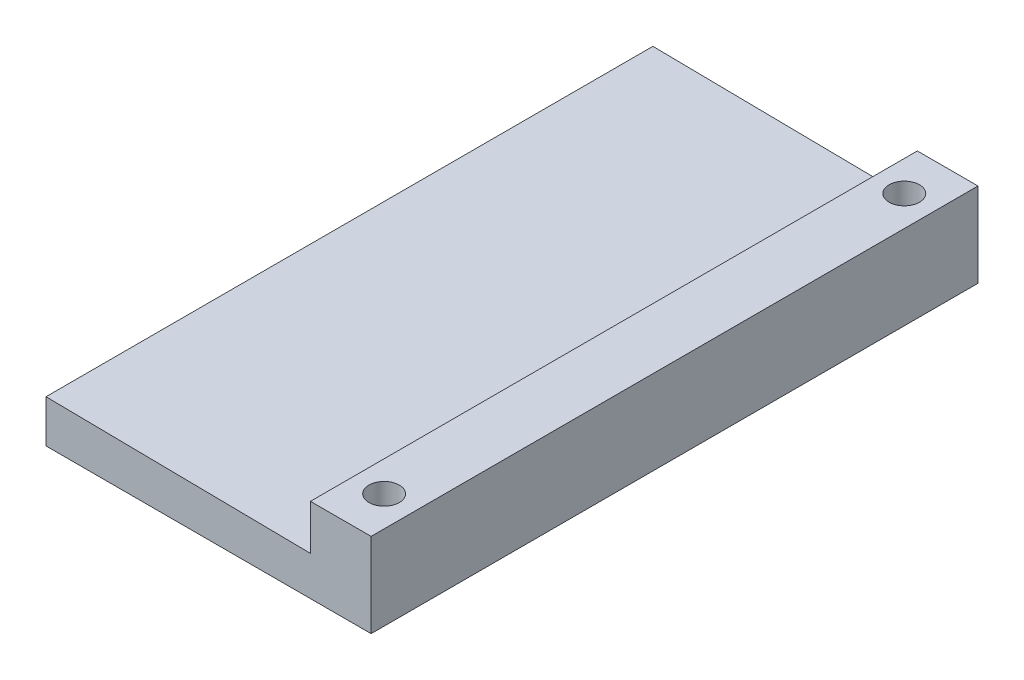
from build123d import *

# Parameters (mm, degrees)
SKETCH1_W               = 41.275
SKETCH1_H               = 88.9
BOSS_EXTRUDE1_DEPTH     = 5.9944
SKETCH1_5_W             = 8.89
SKETCH1_5_H             = 88.9
BOSS_EXTRUDE2_DEPTH     = 12.3444
SKETCH3_R               = 2.2225
CUT_EXTRUDE1_DEPTH      = 1
CUT_EXTRUDE1_DEPTH_BACK = 13.3444
SKETCH4_R               = 3.683
CUT_EXTRUDE2_DEPTH      = 4.064
SKETCH5_W               = 2.54
SKETCH5_H               = 88.9
CUT_EXTRUDE3_DEPTH      = 7.35
CUT_EXTRUDE3_DEPTH_BACK = 6.9944
BOSS_EXTRUDE3_DEPTH     = 88.9
CUT_EXTRUDE4_DEPTH      = 88.9


with BuildPart() as part:
    # Sketch1 → Boss-Extrude1 (new body)
    with BuildSketch(Plane(origin=(0, 0, 0), x_dir=(1, 0, 0), z_dir=(0, 1, 0))):
        with Locations((20.6375, 44.45)):
            Rectangle(SKETCH1_W, SKETCH1_H)
    extrude(amount=BOSS_EXTRUDE1_DEPTH)

    # Sketch1_5 → Boss-Extrude2 (add)
    with BuildSketch(Plane(origin=(0, 0, 0), x_dir=(1, 0, 0), z_dir=(0, 1, 0))):
        with Locations((45.72, 44.45)):
            Rectangle(SKETCH1_5_W, SKETCH1_5_H)
    extrude(amount=BOSS_EXTRUDE2_DEPTH)

    # Sketch3 → Cut-Extrude1 (cut, two sides)
    with BuildSketch(Plane(origin=(0, 12.3444, 0), x_dir=(1, 0, 0), z_dir=(0, 1, 0))) as cut_extrude1_sk:
        with Locations((45.72, 82.55)):
            Circle(SKETCH3_R)
        with Locations((45.72, 6.35)):
            Circle(SKETCH3_R)
    extrude(amount=CUT_EXTRUDE1_DEPTH, mode=Mode.SUBTRACT)
    extrude(cut_extrude1_sk.sketch, amount=-CUT_EXTRUDE1_DEPTH_BACK, mode=Mode.SUBTRACT)

    # Sketch4 → Cut-Extrude2 (cut)
    with BuildSketch(Plane.XZ):
        with Locations((45.72, -6.35)):
            Circle(SKETCH4_R)
        with Locations((45.72, -82.55)):
            Circle(SKETCH4_R)
    extrude(amount=-CUT_EXTRUDE2_DEPTH, mode=Mode.SUBTRACT)

    # Sketch5 → Cut-Extrude3 (cut, two sides)
    with BuildSketch(Plane(origin=(0, 5.9944, 0), x_dir=(1, 0, 0), z_dir=(0, 1, 0))) as cut_extrude3_sk:
        with Locations((1.27, 44.45)):
            Rectangle(SKETCH5_W, SKETCH5_H)
    extrude(amount=CUT_EXTRUDE3_DEPTH, mode=Mode.SUBTRACT)
    extrude(cut_extrude3_sk.sketch, amount=-CUT_EXTRUDE3_DEPTH_BACK, mode=Mode.SUBTRACT)

    # Sketch6 → Boss-Extrude3 (add)
    with BuildSketch(Plane.XY):
        Polygon((2.54, 6.2484), (2.54, 5.9944), (21.9075, 5.9944), align=None)
    extrude(amount=-BOSS_EXTRUDE3_DEPTH)

    # Sketch6_3 → Cut-Extrude4 (cut)
    with BuildSketch(Plane.XY):
        Polygon((41.275, 5.9944), (21.9075, 5.9944), (41.275, 5.7404), align=None)
    extrude(amount=-CUT_EXTRUDE4_DEPTH, mode=Mode.SUBTRACT)


solid = part.part
